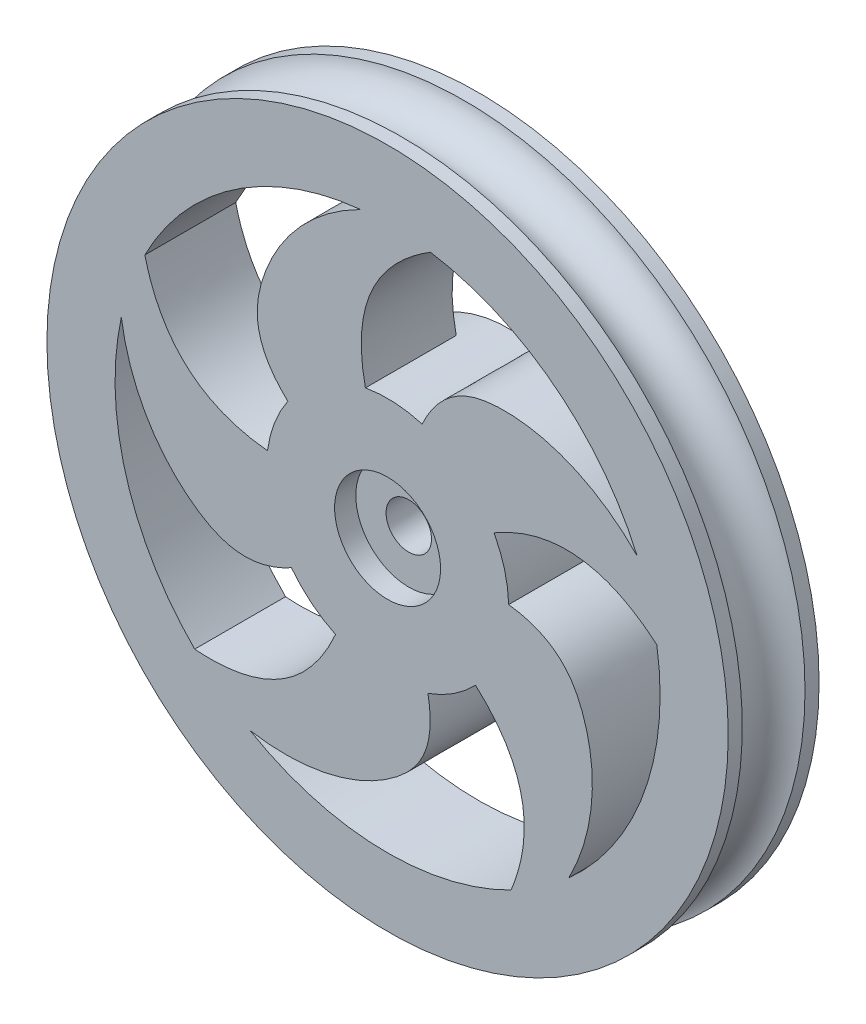
from build123d import *

# Parameters (mm, degrees)
SKETCH1_R               = 28.575
BOSS_EXTRUDE1_DEPTH     = 7.62
SKETCH3_R               = 2.667
SKETCH5_R               = 10.16
BOSS_EXTRUDE3_DEPTH     = 2.54
CUT_EXTRUDE1_DEPTH      = 2.54
CUT_EXTRUDE1_DEPTH_BACK = 2.54
SKETCH6_R               = 1.905
CUT_EXTRUDE2_DEPTH      = 11.16
CUT_EXTRUDE3_DEPTH      = 8.62
SKETCH8_R               = 4.445
CUT_EXTRUDE4_DEPTH      = 1.778


with BuildPart() as part:
    # Sketch1 → Boss-Extrude1 (new body)
    with BuildSketch(Plane.XY):
        Circle(SKETCH1_R)
    extrude(amount=BOSS_EXTRUDE1_DEPTH)

    # Sketch3 → Cut-Revolve1 (revolve, cut)
    with BuildSketch(Plane(origin=(0, 0, 0), x_dir=(0, 0, -1), z_dir=(1, 0, 0))):
        with Locations((-3.81, 29.012456481)):
            Circle(SKETCH3_R)
    revolve(axis=Axis((0, 0, 0), (0, 0, 1)), mode=Mode.SUBTRACT)

    # Sketch5 → Boss-Extrude3 (add)
    with BuildSketch(Plane(origin=(0, 0, 0), x_dir=(-1, 0, 0), z_dir=(0, 0, -1))):
        Circle(SKETCH5_R)
    extrude(amount=BOSS_EXTRUDE3_DEPTH)

    # Sketch4 → Cut-Extrude1 (cut, two sides)
    with BuildSketch(Plane(origin=(0, 0, 0), x_dir=(-1, 0, 0), z_dir=(0, 0, -1))) as cut_extrude1_sk:
        Polygon((7.020938099, 2.976045958), (0.933137647, 7.568333731), (-6.087800452, 4.592287773), (-7.020938099, -2.976045958), (-0.933137647, -7.568333731), (6.087800452, -4.592287773), align=None)
    extrude(amount=CUT_EXTRUDE1_DEPTH, mode=Mode.SUBTRACT)
    extrude(cut_extrude1_sk.sketch, amount=-CUT_EXTRUDE1_DEPTH_BACK, mode=Mode.SUBTRACT)

    # Sketch6 → Cut-Extrude2 (cut, through all)
    with BuildSketch(Plane.XY.offset(7.62)):
        Circle(SKETCH6_R)
    extrude(amount=-CUT_EXTRUDE2_DEPTH, mode=Mode.SUBTRACT)

    # Sketch7 → Cut-Extrude3 (cut, through all)
    with BuildSketch(Plane(origin=(0, 0, 0), x_dir=(-1, 0, 0), z_dir=(0, 0, -1))):
        with BuildLine():
            ThreePointArc((20.358331305, 10.397977999), (12.886311534, 18.881805397), (2.2627084, 22.747741661))
            add(Edge.make_bspline(
                [(2.2627084, 22.747741661), (6.405747391, 20.68512775), (11.177081783, 15.102097432), (11.330348043, 8.533524003), (8.367773099, 5.762462439)],
                knots=[0, 0, 0, 0, 0.593726926, 1, 1, 1, 1], degree=3))
            ThreePointArc((8.367773099, 5.762462439), (9.485052986, 3.641341765), (10.074217449, 1.317475913))
            add(Edge.make_bspline(
                [(20.358331305, 10.397977999), (18.357588554, 2.14920895), (10.074217449, 1.317475913)],
                knots=[0, 0, 0, 1, 1, 1], degree=2))
        make_face()
        with BuildLine():
            ThreePointArc((16.180135083, -16.14877174), (21.939753321, -6.420811804), (22.333603287, 4.877475189))
            add(Edge.make_bspline(
                [(22.333603287, 4.877475189), (21.652210342, 0.299828208), (17.81685639, -5.963231706), (11.617133708, -8.1387974), (8.066211545, -6.17752631)],
                knots=[0, 0, 0, 0, 0.593726926, 1, 1, 1, 1], degree=3))
            ThreePointArc((8.066211545, -6.17752631), (6.394164379, -7.895584962), (4.366098449, -9.174027705))
            add(Edge.make_bspline(
                [(16.180135083, -16.14877174), (7.716826016, -16.794962128), (4.366098449, -9.174027705)],
                knots=[0, 0, 0, 1, 1, 1], degree=2))
        make_face()
        with BuildLine():
            ThreePointArc((-10.358457881, -20.378467811), (0.673201723, -22.850085327), (11.540217523, -19.733296216))
            add(Edge.make_bspline(
                [(11.540217523, -19.733296216), (6.976054533, -20.499823727), (-0.165658961, -18.787577309), (-4.15056456, -13.563577423), (-3.382580204, -9.580383665)],
                knots=[0, 0, 0, 0, 0.593726926, 1, 1, 1, 1], degree=3))
            ThreePointArc((-3.382580204, -9.580383665), (-5.533242071, -8.521081633), (-7.37582021, -6.987336849))
            add(Edge.make_bspline(
                [(-10.358457881, -20.378467811), (-13.588327791, -12.529066385), (-7.37582021, -6.987336849)],
                knots=[0, 0, 0, 1, 1, 1], degree=2))
        make_face()
        with BuildLine():
            ThreePointArc((-22.582014125, 3.554185994), (-21.523691775, -7.701317574), (-15.201356621, -17.07332296))
            add(Edge.make_bspline(
                [(-15.201356621, -17.07332296), (-17.340771534, -12.969416034), (-17.919239259, -5.648129637), (-14.182323678, -0.243954457), (-10.156761081, 0.25652358)],
                knots=[0, 0, 0, 0, 0.593726926, 1, 1, 1, 1], degree=3))
            ThreePointArc((-10.156761081, 0.25652358), (-9.813896046, 2.629266893), (-8.924606034, 4.855616042))
            add(Edge.make_bspline(
                [(-22.582014125, 3.554185994), (-16.114874441, 9.051573254), (-8.924606034, 4.855616042)],
                knots=[0, 0, 0, 1, 1, 1], degree=2))
        make_face()
        with BuildLine():
            ThreePointArc((-3.597994382, 22.575075557), (-13.975574803, 18.090409308), (-20.935172589, 9.181402325))
            add(Edge.make_bspline(
                [(-20.935172589, 9.181402325), (-17.693240732, 12.484283803), (-10.909039954, 15.29684122), (-4.614593512, 13.412805277), (-2.89464336, 9.738923956)],
                knots=[0, 0, 0, 0, 0.593726926, 1, 1, 1, 1], degree=3))
            ThreePointArc((-2.89464336, 9.738923956), (-0.532079248, 10.146057938), (1.860110345, 9.988272599))
            add(Edge.make_bspline(
                [(-3.597994382, 22.575075557), (3.628787662, 18.123246308), (1.860110345, 9.988272599)],
                knots=[0, 0, 0, 1, 1, 1], degree=2))
        make_face()
    extrude(amount=-CUT_EXTRUDE3_DEPTH, mode=Mode.SUBTRACT)

    # Sketch8 → Cut-Extrude4 (cut)
    with BuildSketch(Plane.XY.offset(7.62)):
        Circle(SKETCH8_R)
    extrude(amount=-CUT_EXTRUDE4_DEPTH, mode=Mode.SUBTRACT)


solid = part.part
